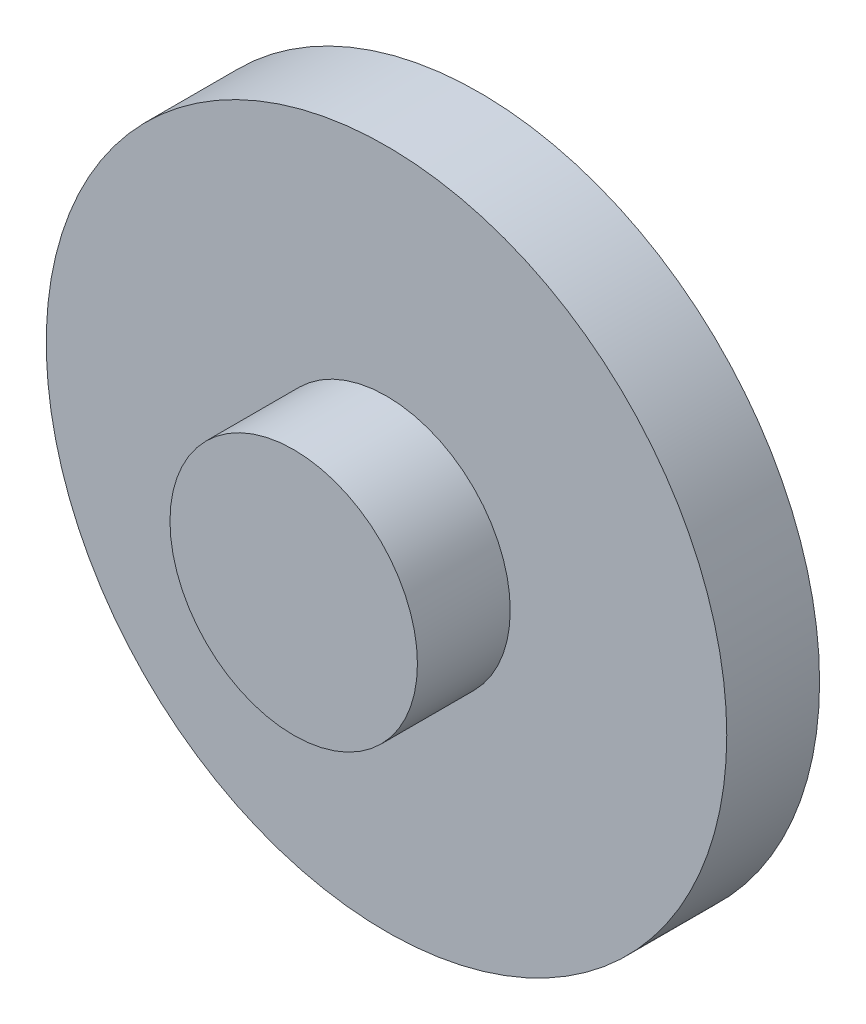
from build123d import *

# Parameters (mm, degrees)
SKETCH1_R           = 11
BOSS_EXTRUDE1_DEPTH = 3
SKETCH2_R           = 4
BOSS_EXTRUDE2_DEPTH = 3


with BuildPart() as part:
    # Sketch1 → Boss-Extrude1 (new body)
    with BuildSketch(Plane.XY):
        Circle(SKETCH1_R)
    extrude(amount=BOSS_EXTRUDE1_DEPTH)

    # Sketch2 → Boss-Extrude2 (add)
    with BuildSketch(Plane.XY.offset(3)):
        Circle(SKETCH2_R)
    extrude(amount=BOSS_EXTRUDE2_DEPTH)


solid = part.part
